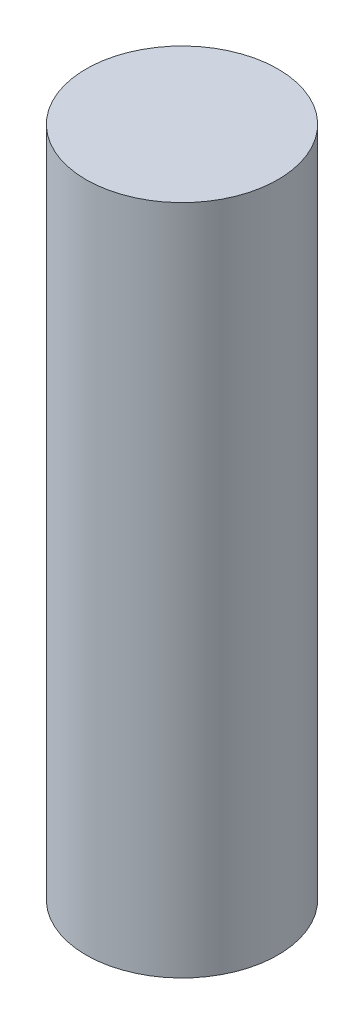
from build123d import *

# Parameters (mm, degrees)
CROQUIS1_R              = 2
SALIENTE_EXTRUIR1_DEPTH = 14


with BuildPart() as part:
    # Croquis1 → Saliente-Extruir1 (new body)
    with BuildSketch(Plane(origin=(0, 0, 0), x_dir=(1, 0, 0), z_dir=(0, 1, 0))):
        Circle(CROQUIS1_R)
    extrude(amount=SALIENTE_EXTRUIR1_DEPTH)


solid = part.part
